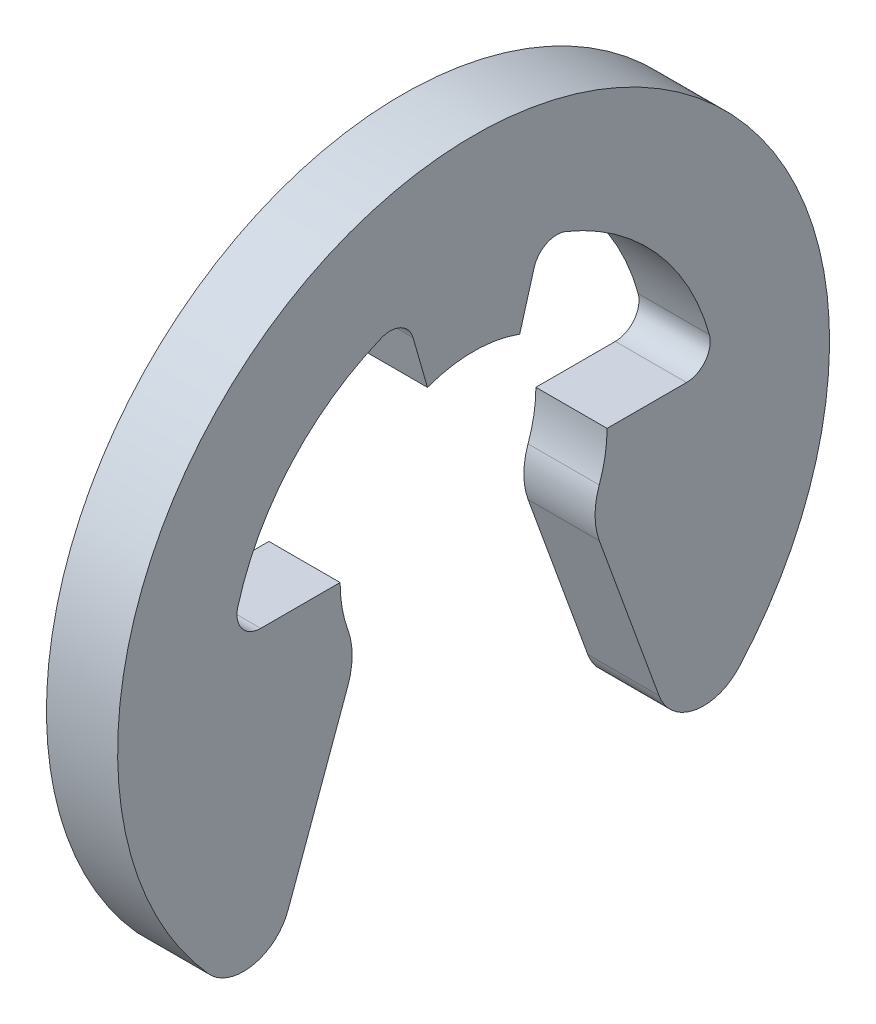
from build123d import *

# Parameters (mm, degrees)
BASE_EXTRUSION_DEPTH = 0.4


with BuildPart() as part:
    # Esquisse1 → Base-Extrusion (new body)
    with BuildSketch(Plane(origin=(0, 0, 0), x_dir=(0, 0, -1), z_dir=(1, 0, 0))):
        with BuildLine():
            Line((0.259160739, 0.903800903), (0.340270753, 1.186665137))
            ThreePointArc((0.340270753, 1.186665137), (0.410161537, 1.269836455), (0.518741151, 1.273394133))
            ThreePointArc((0.518741151, 1.273394133), (1.026563801, 0.914763228), (1.324526284, 0.369127517))
            ThreePointArc((1.324526284, 0.369127517), (1.302271964, 0.252694571), (1.196087371, 0.2))
            Line((1.196087371, 0.2), (0.75, 0.2))
            ThreePointArc((0.75, 0.2), (0.738894958, 0.071414458), (0.705908689, -0.053363222))
            ThreePointArc((0.705908689, -0.053363222), (0.682394322, -0.189383994), (0.706516275, -0.325298332))
            Line((0.706516275, -0.325298332), (1.041746298, -1.246335251))
            ThreePointArc((1.041746298, -1.246335251), (1.241925107, -1.416989302), (1.491151151, -1.332842168))
            ThreePointArc((1.491151151, -1.332842168), (0, 2), (-1.491151151, -1.332842168))
            ThreePointArc((-1.491151151, -1.332842168), (-1.241925107, -1.416989302), (-1.041746298, -1.246335251))
            Line((-1.041746298, -1.246335251), (-0.706516275, -0.325298332))
            ThreePointArc((-0.706516275, -0.325298332), (-0.682394322, -0.189383994), (-0.705908689, -0.053363222))
            ThreePointArc((-0.705908689, -0.053363222), (-0.738894958, 0.071414458), (-0.75, 0.2))
            Line((-0.75, 0.2), (-1.196087371, 0.2))
            ThreePointArc((-1.196087371, 0.2), (-1.302271964, 0.252694571), (-1.324526284, 0.369127517))
            ThreePointArc((-1.324526284, 0.369127517), (-1.026563801, 0.914763228), (-0.518741151, 1.273394133))
            ThreePointArc((-0.518741151, 1.273394133), (-0.410161537, 1.269836455), (-0.340270753, 1.186665137))
            Line((-0.340270753, 1.186665137), (-0.259160739, 0.903800903))
            ThreePointArc((-0.259160739, 0.903800903), (0, 0.95), (0.259160739, 0.903800903))
        make_face()
    extrude(amount=BASE_EXTRUSION_DEPTH)


solid = part.part
